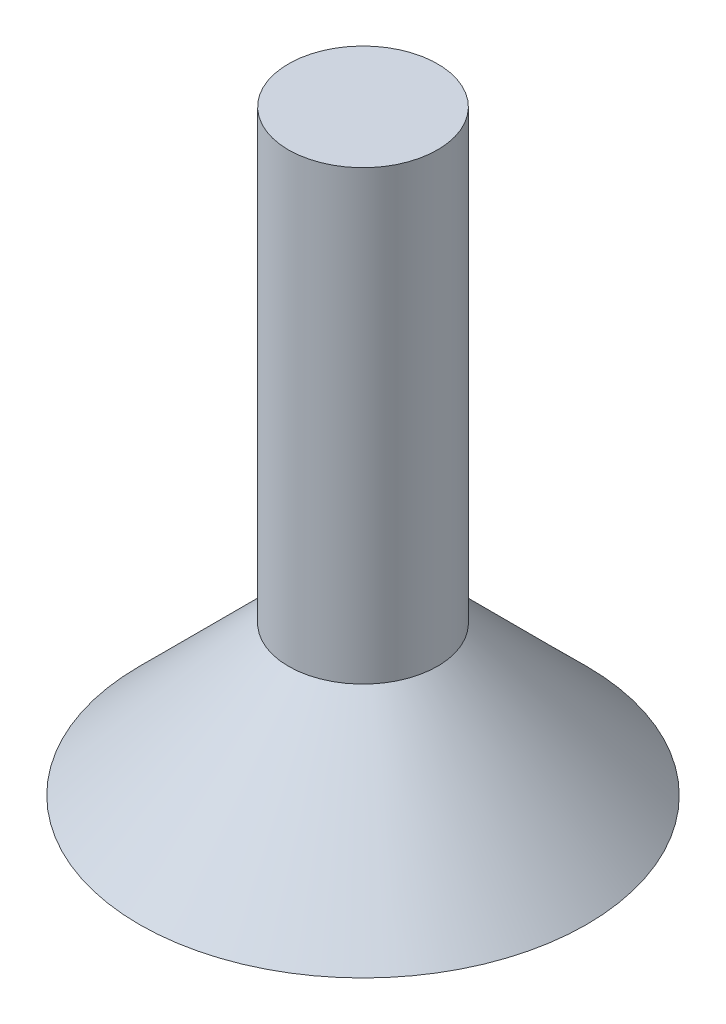
from build123d import *


with BuildPart() as part:
    # Sketch1 → Revolve1 (revolve)
    with BuildSketch(Plane(origin=(0, 0, 0), x_dir=(0, 0, -1), z_dir=(1, 0, 0))):
        Polygon((15, 0), (5, 10), (5, 40), (0, 40), (0, 0), align=None)
    revolve(axis=Axis((0, 40, 0), (0, -1, 0)))


solid = part.part
